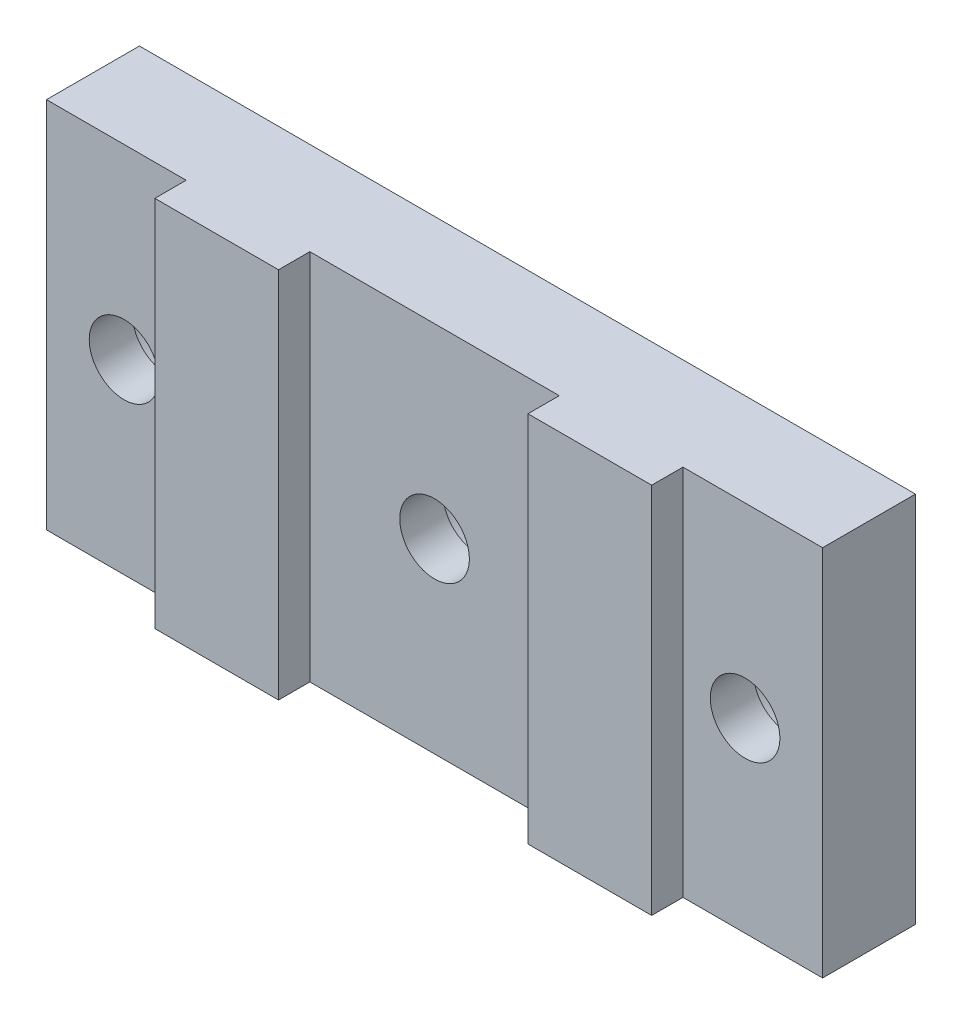
from build123d import *

# Parameters (mm, degrees)
SKETCH1_W          = 39.6748
SKETCH1_H          = 19.05
EXTRUDE1_DEPTH     = 6.35
SKETCH2_W          = 7.1374
SKETCH2_H          = 1.6002
SKETCH2_W_2        = 12.7508
CUT_EXTRUDE1_DEPTH = 20.05
HOLE1_D            = 3.556
HOLE1_CBORE_D      = 6.35
HOLE1_CBORE_DEPTH  = 2.54


with BuildPart() as part:
    # Sketch1 → Extrude1 (new body)
    with BuildSketch(Plane.XY):
        with Locations((19.8374, 9.525)):
            Rectangle(SKETCH1_W, SKETCH1_H)
    extrude(amount=EXTRUDE1_DEPTH)

    # Sketch2 → Cut-Extrude1 (cut, through all)
    with BuildSketch(Plane.XZ):
        with Locations((3.5687, 5.5499)):
            Rectangle(SKETCH2_W, SKETCH2_H)
        with Locations((19.8374, 5.5499)):
            Rectangle(SKETCH2_W_2, SKETCH2_H)
        with Locations((36.1061, 5.5499)):
            Rectangle(SKETCH2_W, SKETCH2_H)
    extrude(amount=-CUT_EXTRUDE1_DEPTH, mode=Mode.SUBTRACT)

    # Hole1 (through all)
    with Locations(Plane(origin=(0, 0, 0), x_dir=(-1, 0, 0), z_dir=(0, 0, -1))):
        with Locations((-3.9624, 9.525), (-19.8374, 9.525), (-35.7124, 9.525)):
            CounterBoreHole(HOLE1_D / 2, HOLE1_CBORE_D / 2, HOLE1_CBORE_DEPTH)


solid = part.part
